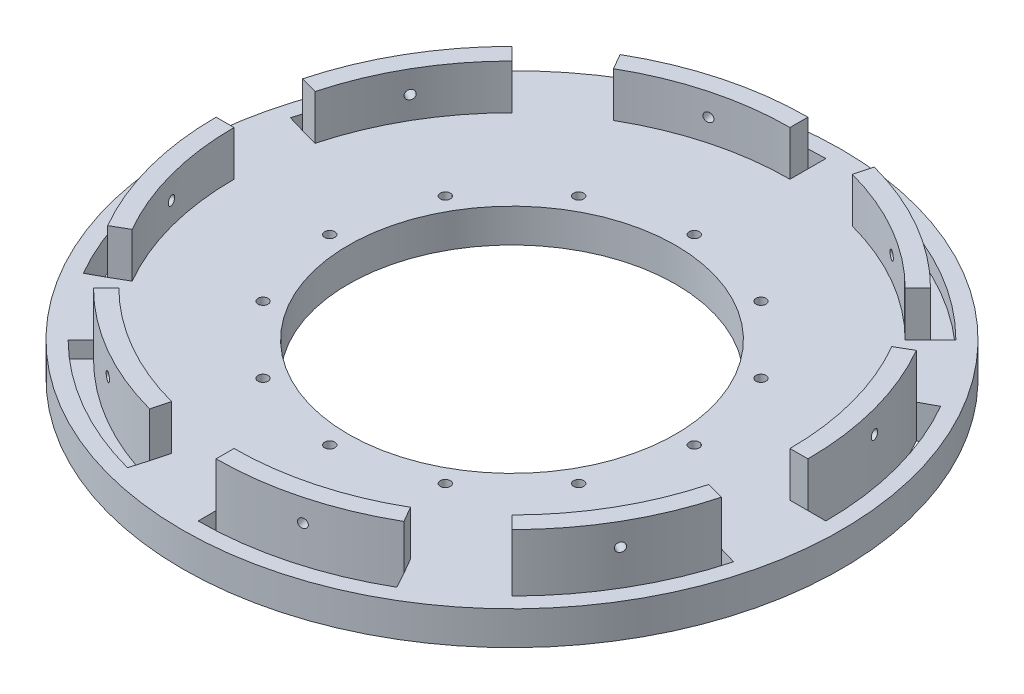
from build123d import *

# Parameters (mm, degrees)
SKETCH1_W                      = 127.635
SKETCH1_H                      = 127.635
BOSS_EXTRUDE1_DEPTH            = 9.525
SKETCH12_R                     = 93.345
BOSS_EXTRUDE2_DEPTH            = 9.525
SKETCH5_R                      = 46.355
CUT_EXTRUDE1_DEPTH             = 9.525
SKETCH11_R                     = 1.4351
CUT_EXTRUDE3_DEPTH             = 10.525
CIRPATTERN1_COUNT              = 12
BOTTOM_SUPPORT_HOLE_DEPTH      = 10.525
BOTTOM_SUPPORT_GUIDE_DEPTH     = 12.7
SKETCH16_R                     = 1.27
BOTTOM_SUPPORT_BOLT_HOLE_DEPTH = 12.7
TOP_SUPPORT_HOLE_DEPTH         = 4.7625
TOP_SUPPORT_GUIDE_DEPTH        = 12.7
SKETCH29_R                     = 1.27
TOP_SUPPORT_BOLT_HOLE_DEPTH    = 12.7
CIRPATTERN4_COUNT              = 4


with BuildPart() as part:
    # Sketch1 → Boss-Extrude1 (new body)
    with BuildSketch(Plane(origin=(0, 0, 0), x_dir=(1, 0, 0), z_dir=(0, 1, 0))):
        with Locations((63.8175, 63.8175)):
            Rectangle(SKETCH1_W, SKETCH1_H)
    extrude(amount=BOSS_EXTRUDE1_DEPTH)

    # Sketch12 → Boss-Extrude2 (add)
    with BuildSketch(Plane.XZ):
        with Locations((63.8175, -63.8175)):
            Circle(SKETCH12_R)
    extrude(amount=-BOSS_EXTRUDE2_DEPTH)

    # Sketch5 → Cut-Extrude1 (cut)
    with BuildSketch(Plane(origin=(0, 9.525, 0), x_dir=(1, 0, 0), z_dir=(0, 1, 0))):
        with Locations((63.8175, 63.8175)):
            Circle(SKETCH5_R)
    extrude(amount=-CUT_EXTRUDE1_DEPTH, mode=Mode.SUBTRACT)

    # Sketch11 → Cut-Extrude3 (cut, through all)
    with BuildSketch(Plane(origin=(0, 9.525, 0), x_dir=(1, 0, 0), z_dir=(0, 1, 0))):
        with Locations((63.8175, 115.443)):
            Circle(SKETCH11_R)
    cut_extrude3 = extrude(amount=-CUT_EXTRUDE3_DEPTH, mode=Mode.SUBTRACT)

    # CirPattern1: Cut-Extrude3 ×12 about axis
    cirpattern1_axis = Axis((63.8175, 0, -63.8175), (0, 1, 0))
    for i in range(1, CIRPATTERN1_COUNT):
        add(cut_extrude3.rotate(cirpattern1_axis, i * 360 / CIRPATTERN1_COUNT), mode=Mode.SUBTRACT)

    # Sketch14 → Bottom support hole (cut, through all)
    with BuildSketch(Plane.XZ.offset(-9.525)):
        with BuildLine():
            Line((147.6375, -63.8175), (152.7175, -63.8175))
            ThreePointArc((152.7175, -63.8175), (149.696832172, -86.794669228), (140.840102796, -108.21038973))
            Line((140.840102796, -108.21038973), (136.380758996, -105.774213931))
            ThreePointArc((136.380758996, -105.774213931), (144.774416842, -85.53776739), (147.6375, -63.8175))
        make_face()
    bottom_support_hole = extrude(amount=BOTTOM_SUPPORT_HOLE_DEPTH, mode=Mode.SUBTRACT)

    # Sketch15 → Bottom support guide (add)
    with BuildSketch(Plane.XZ.offset(-9.525)):
        with BuildLine():
            Line((142.5575, -63.8175), (147.6375, -63.8175))
            ThreePointArc((147.6375, -63.8175), (144.774416842, -85.53776739), (136.380758996, -105.774213931))
            Line((136.380758996, -105.774213931), (131.982985723, -103.231382784))
            ThreePointArc((131.982985723, -103.231382784), (139.867937033, -84.221387548), (142.5575, -63.8175))
        make_face()
    bottom_support_guide = extrude(amount=-BOTTOM_SUPPORT_GUIDE_DEPTH)

    # Sketch16 → Bottom support bolt hole (cut, symmetric)
    with BuildSketch(Plane(origin=(153.69605101, 0, -41.235751742), x_dir=(-0.25912989, 0, -0.965842482), z_dir=(0.965842482, 0, -0.25912989))):
        with Locations((45.103898223, 15.875)):
            Circle(SKETCH16_R)
    bottom_support_bolt_hole = extrude(amount=BOTTOM_SUPPORT_BOLT_HOLE_DEPTH, both=True, mode=Mode.SUBTRACT)

    # Sketch25 → Top support hole (cut)
    with BuildSketch(Plane.XZ.offset(-9.525)):
        with BuildLine():
            Line((123.087190399, -4.547809601), (126.679292847, -0.955707153))
            ThreePointArc((126.679292847, -0.955707153), (140.790670316, -19.338954031), (149.671218106, -40.744808623))
            Line((149.671218106, -40.744808623), (144.795349438, -42.175404436))
            ThreePointArc((144.795349438, -42.175404436), (136.421233243, -21.930863478), (123.087190399, -4.547809601))
        make_face()
    top_support_hole = extrude(amount=TOP_SUPPORT_HOLE_DEPTH, mode=Mode.SUBTRACT)

    # Sketch27 → Top support guide (add)
    with BuildSketch(Plane(origin=(-7.938423225, 9.525, 69.121219833), x_dir=(1, 0, 0), z_dir=(0, -1, 0))):
        with BuildLine():
            Line((131.025613624, -73.669029434), (127.433511176, -77.261131883))
            ThreePointArc((127.433511176, -77.261131883), (139.959430211, -93.590667343), (147.826024212, -112.608266425))
            Line((147.826024212, -112.608266425), (152.733772663, -111.296624269))
            ThreePointArc((152.733772663, -111.296624269), (144.359656468, -91.052083311), (131.025613624, -73.669029434))
        make_face()
    top_support_guide = extrude(amount=-TOP_SUPPORT_GUIDE_DEPTH)

    # Sketch29 → Top support bolt hole (cut, symmetric)
    with BuildSketch(Plane(origin=(90.381164695, 0, 52.142814494), x_dir=(-0.499721266, 0, 0.866186271), z_dir=(-0.866186271, 0, -0.499721266))):
        with Locations((-87.172071643, 15.875)):
            Circle(SKETCH29_R)
    top_support_bolt_hole = extrude(amount=TOP_SUPPORT_BOLT_HOLE_DEPTH, both=True, mode=Mode.SUBTRACT)

    # CirPattern4: Bottom support hole, Bottom support guide, Bottom support bolt hole, Top support hole, Top support guide, Top support bolt hole ×4 about axis
    cirpattern4_axis = Axis((63.8175, 0, -63.8175), (0, 1, 0))
    for i in range(1, CIRPATTERN4_COUNT):
        add(bottom_support_hole.rotate(cirpattern4_axis, i * 360 / CIRPATTERN4_COUNT), mode=Mode.SUBTRACT)
        add(bottom_support_guide.rotate(cirpattern4_axis, i * 360 / CIRPATTERN4_COUNT))
        add(bottom_support_bolt_hole.rotate(cirpattern4_axis, i * 360 / CIRPATTERN4_COUNT), mode=Mode.SUBTRACT)
        add(top_support_hole.rotate(cirpattern4_axis, i * 360 / CIRPATTERN4_COUNT), mode=Mode.SUBTRACT)
        add(top_support_guide.rotate(cirpattern4_axis, i * 360 / CIRPATTERN4_COUNT))
        add(top_support_bolt_hole.rotate(cirpattern4_axis, i * 360 / CIRPATTERN4_COUNT), mode=Mode.SUBTRACT)


solid = part.part
